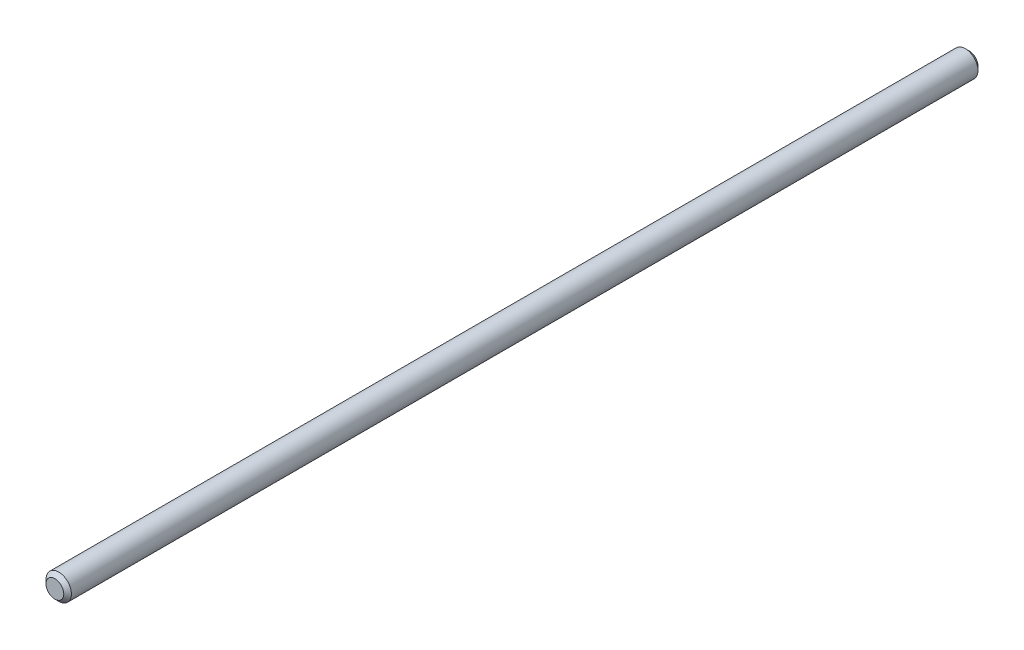
from build123d import *

# Parameters (mm, degrees)
SKETCH2_W     = 228.6
SKETCH2_H     = 3.175
CHAMFER1_SIZE = 0.9525


with BuildPart() as part:
    # Sketch2 → Revolve1 (revolve)
    with BuildSketch(Plane(origin=(0, 0, 0), x_dir=(0, 0, -1), z_dir=(1, 0, 0))):
        with Locations((0, 1.5875)):
            Rectangle(SKETCH2_W, SKETCH2_H)
    revolve(axis=Axis((0, 0, 114.3), (0, 0, -1)))

    # Chamfer1
    chamfer1_edges = [part.edges().sort_by_distance(p)[0] for p in [
        (0, -3.175, -114.3),
        (0, -3.175, 114.3),
    ]]
    chamfer(chamfer1_edges, length=CHAMFER1_SIZE)


solid = part.part
